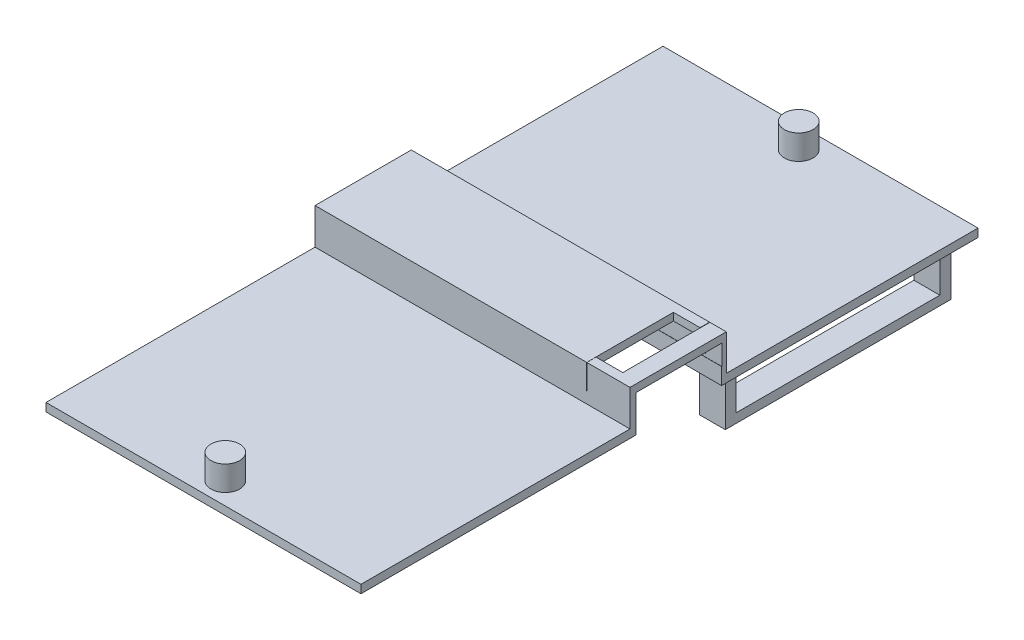
from build123d import *

# Parameters (mm, degrees)
CROQUIS1_W              = 45
CROQUIS1_H              = 75
SALIENTE_EXTRUIR1_DEPTH = 1
CROQUIS2_W              = 45
CROQUIS2_H              = 11.7
SALIENTE_EXTRUIR2_DEPTH = 1.38
CROQUIS5_W              = 6.714746972
CROQUIS5_H              = 75
CORTAR_EXTRUIR2_DEPTH   = 38.3
CROQUIS7_R              = 1.75
CROQUIS7_R_2            = 1.745
SALIENTE_EXTRUIR3_DEPTH = 3
CROQUIS8_W              = 10.404122083
CROQUIS8_H              = 2.00964754
CORTAR_EXTRUIR3_DEPTH   = 40
CROQUIS9_W              = 3.216312559
CROQUIS9_H              = 9.421023217
CORTAR_EXTRUIR5_DEPTH   = 10
CROQUIS10_W             = 3.147375437
CROQUIS10_H             = 27.45813743
CROQUIS10_W_2           = 3.03884525
SALIENTE_EXTRUIR4_DEPTH = 7
CROQUIS11_W             = 24.765018181
CROQUIS11_H             = 4.681943735
CORTAR_EXTRUIR6_DEPTH   = 47
SALIENTE_EXTRUIR5_DEPTH = 3
CROQUIS13_W             = 10.418820836
CROQUIS13_H             = 2.453250219
CORTAR_EXTRUIR7_DEPTH   = 43


with BuildPart() as part:
    # Croquis1 → Saliente-Extruir1 (new body)
    with BuildSketch(Plane(origin=(0, 0, 0), x_dir=(1, 0, 0), z_dir=(0, 1, 0))):
        Rectangle(CROQUIS1_W, CROQUIS1_H)
    extrude(amount=SALIENTE_EXTRUIR1_DEPTH)

    # Croquis2 → Saliente-Extruir2 (add)
    with BuildSketch(Plane(origin=(0, 1, 0), x_dir=(1, 0, 0), z_dir=(0, 1, 0))):
        with Locations((0, 1.05)):
            Rectangle(CROQUIS2_W, CROQUIS2_H)
    extrude(amount=SALIENTE_EXTRUIR2_DEPTH)

    # Croquis5 → Cortar-Extruir2 (cut)
    with BuildSketch(Plane.XZ):
        with Locations((19.142626514, 0)):
            Rectangle(CROQUIS5_W, CROQUIS5_H)
    extrude(amount=-CORTAR_EXTRUIR2_DEPTH, mode=Mode.SUBTRACT)

    # Croquis7 → Saliente-Extruir3 (add)
    with BuildSketch(Plane(origin=(0, 1, 0), x_dir=(1, 0, 0), z_dir=(0, 1, 0))):
        with Locations((-3.357373486, 34.85)):
            Circle(CROQUIS7_R)
        with Locations((-3.357373486, -34.85)):
            Circle(CROQUIS7_R_2)
    extrude(amount=SALIENTE_EXTRUIR3_DEPTH)

    # Croquis8 → Cortar-Extruir3 (cut)
    with BuildSketch(Plane.ZY.offset(22.5)):
        with Locations((-1.128567076, 1.00482377)):
            Rectangle(CROQUIS8_W, CROQUIS8_H)
    extrude(amount=-CORTAR_EXTRUIR3_DEPTH, mode=Mode.SUBTRACT)

    # Croquis9 → Cortar-Extruir5 (cut)
    with BuildSketch(Plane.XZ.offset(-2.00964754)):
        with Locations((12.147096749, -1.030456008)):
            Rectangle(CROQUIS9_W, CROQUIS9_H)
    extrude(amount=-CORTAR_EXTRUIR5_DEPTH, mode=Mode.SUBTRACT)

    # Croquis10 → Saliente-Extruir4 (add)
    with BuildSketch(Plane.XZ):
        with Locations((12.079419824, -22.642531368)):
            Rectangle(CROQUIS10_W, CROQUIS10_H)
        with Locations((-19.448599637, -22.642531368)):
            Rectangle(CROQUIS10_W_2, CROQUIS10_H)
    extrude(amount=SALIENTE_EXTRUIR4_DEPTH)

    # Croquis11 → Cortar-Extruir6 (cut)
    with BuildSketch(Plane(origin=(13.653107542, 0, 0), x_dir=(0, 0, -1), z_dir=(1, 0, 0))):
        with Locations((22.608859882, -3.539167372)):
            Rectangle(CROQUIS11_W, CROQUIS11_H)
    extrude(amount=-CORTAR_EXTRUIR6_DEPTH, mode=Mode.SUBTRACT)

    # Croquis12 → Saliente-Extruir5 (add)
    with BuildSketch(Plane(origin=(0, 2.38, 0), x_dir=(1, 0, 0), z_dir=(0, 1, 0))):
        Polygon((10.521558479, 6.9), (-22.5, 6.9), (-22.5, -4.8), (10.521558479, -4.8), (10.521558479, 5.740967616), align=None)
        Polygon((13.755253028, 6.9), (10.521558479, 6.9), (10.521558479, 5.740967616), (10.538940469, 5.740967616), (13.755253028, 5.740967616), align=None)
        Polygon((15.785253028, 6.9), (13.792175248, 6.9), (13.792175248, -3.680055601), (13.792175248, -4.8), (15.785253028, -4.8), align=None)
        Polygon((10.538940469, -3.680055601), (10.538940469, -4.8), (13.792175248, -4.8), (13.792175248, -3.680055601), (13.755253028, -3.680055601), align=None)
    extrude(amount=SALIENTE_EXTRUIR5_DEPTH)

    # Croquis13 → Cortar-Extruir7 (cut)
    with BuildSketch(Plane(origin=(15.785253028, 0, 0), x_dir=(0, 0, -1), z_dir=(1, 0, 0))):
        with Locations((1.143850221, 3.23627265)):
            Rectangle(CROQUIS13_W, CROQUIS13_H)
    extrude(amount=-CORTAR_EXTRUIR7_DEPTH, mode=Mode.SUBTRACT)


solid = part.part
